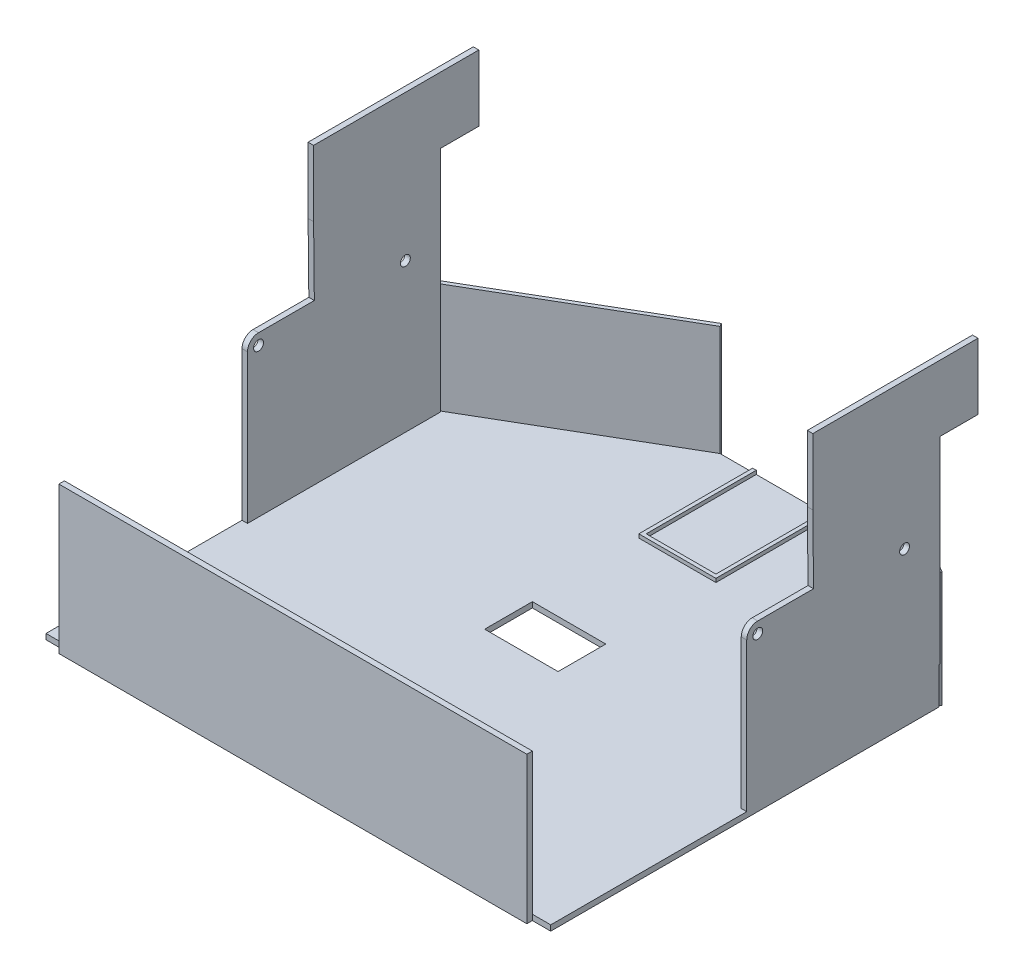
from build123d import *

# Parameters (mm, degrees)
SKETCH1_W                = 134
SKETCH1_H                = 134
SKETCH1_W_2              = 20
SKETCH1_H_2              = 13
BOSS_EXTRUDE1_DEPTH      = 1.5
BOSS_EXTRUDE2_DEPTH      = 45
SKETCH2_R                = 1.35
CUT_EXTRUDE1_DEPTH       = 137.5
SKETCH3_W                = 53.4
SKETCH3_H                = 43.5
CUT_EXTRUDE2_DEPTH       = 137.5
SKETCH4_W                = 140
SKETCH4_H                = 5
CUT_EXTRUDE3_DEPTH       = 1.5
SKETCH5_W                = 30
SKETCH5_H                = 43.5
CUT_EXTRUDE4_DEPTH       = 137.5
CUT_EXTRUDE5_DEPTH       = 10
BOSS_EXTRUDE3_DEPTH      = 1.5
BOSS_EXTRUDE4_DEPTH      = 1
BOSS_EXTRUDE5_DEPTH      = 30
BOSS_EXTRUDE5_DEPTH_BACK = 1.5
CUT_EXTRUDE6_DEPTH       = 137.5
SKETCH11_W               = 5
SKETCH11_H               = 40
CUT_EXTRUDE7_DEPTH       = 1.5
BOSS_EXTRUDE6_DEPTH      = 1.5


with BuildPart() as part:
    # Sketch1 → Boss-Extrude1 (new body)
    with BuildSketch(Plane(origin=(0, 0, 0), x_dir=(1, 0, 0), z_dir=(0, 1, 0))):
        Rectangle(SKETCH1_W, SKETCH1_H)
        Rectangle(SKETCH1_W_2, SKETCH1_H_2, mode=Mode.SUBTRACT)
        Polygon((-67, 67), (-67.25, 67.25), (-67.25, -67.25), (67.25, -67.25), (67.25, 67.25), (67, 67), (67, -67), (-67, -67), align=None)
    extrude(amount=BOSS_EXTRUDE1_DEPTH)

    # Sketch1_3 → Boss-Extrude2 (add)
    with BuildSketch(Plane(origin=(0, 0, 0), x_dir=(1, 0, 0), z_dir=(0, 1, 0))):
        Polygon((-67.25, -67.25), (-67.25, 67.25), (-68.75, 68.75), (-68.75, -68.75), (68.75, -68.75), (68.75, 68.75), (67.25, 67.25), (67.25, -67.25), align=None)
    extrude(amount=BOSS_EXTRUDE2_DEPTH)

    # Sketch2 → Cut-Extrude1 (cut)
    with BuildSketch(Plane.ZY.offset(68.75)):
        with Locations((10.85, 42)):
            Circle(SKETCH2_R)
        with Locations((-29.15, 42)):
            Circle(SKETCH2_R)
    extrude(amount=-CUT_EXTRUDE1_DEPTH, mode=Mode.SUBTRACT)

    # Sketch3 → Cut-Extrude2 (cut)
    with BuildSketch(Plane.ZY.offset(68.75)):
        with Locations((40.55, 23.25)):
            Rectangle(SKETCH3_W, SKETCH3_H)
    extrude(amount=-CUT_EXTRUDE2_DEPTH, mode=Mode.SUBTRACT)

    # Sketch4 → Cut-Extrude3 (cut)
    with BuildSketch(Plane.XY.offset(68.75)):
        with Locations((0, 42.5)):
            Rectangle(SKETCH4_W, SKETCH4_H)
    extrude(amount=-CUT_EXTRUDE3_DEPTH, mode=Mode.SUBTRACT)

    # Sketch5 → Cut-Extrude4 (cut)
    with BuildSketch(Plane.ZY.offset(68.75)):
        with Locations((-53.75, 23.25)):
            Rectangle(SKETCH5_W, SKETCH5_H)
    extrude(amount=-CUT_EXTRUDE4_DEPTH, mode=Mode.SUBTRACT)

    # Sketch6 → Cut-Extrude5 (cut)
    with BuildSketch(Plane(origin=(0, 0, 0), x_dir=(-1, 0, 0), z_dir=(0, -1, 0))):
        Polygon((67, 67), (68.75, 67), (68.75, 68.75), align=None)
        Polygon((19.386551984, 67), (68.75, 38.5), (68.75, 67), (67, 67), align=None)
        Polygon((-68.75, 38.5), (-19.386551984, 67), (-67, 67), (-68.75, 67), align=None)
        Polygon((-68.75, 67), (-67, 67), (-68.75, 68.75), align=None)
    extrude(amount=-CUT_EXTRUDE5_DEPTH, mode=Mode.SUBTRACT)


with BuildPart() as body_2:
    # Sketch7 → Boss-Extrude3 (new body)
    with BuildSketch(Plane(origin=(-68.75, 0, 0), x_dir=(0, 0, -1), z_dir=(-1, 0, 0))):
        Polygon((49.15, -63.7), (38.75, -63.7), (38.75, -45), (19.55, -45), (19.55, -63.7), (4.15, -63.7), (4.15, -81.7), (49.15, -81.7), align=None)
    boss_extrude3 = extrude(amount=-BOSS_EXTRUDE3_DEPTH)


with BuildPart() as part_1:
    add(part.part)

    # Mirror6: Boss-Extrude3 across plane
    add(boss_extrude3.mirror(Plane(origin=(0, 0, 0), x_dir=(0, 0, 1), z_dir=(1, 0, 0))))


with BuildPart() as body_2_1:
    add(body_2.part)

    # Combine1: union part
    add(part_1.part)

    # Sketch8 → Boss-Extrude4 (add)
    with BuildSketch(Plane(origin=(0, 1.5, 0), x_dir=(1, 0, 0), z_dir=(0, 1, 0))):
        Polygon((-9.5, 37), (-9.5, 67), (-10.5, 67), (-10.5, 36), (0, 36), (0, 37), align=None)
        Polygon((10.5, 67), (9.5, 67), (9.5, 37), (0, 37), (0, 36), (10.5, 36), align=None)
    extrude(amount=BOSS_EXTRUDE4_DEPTH)

    # Sketch9 → Boss-Extrude5 (add, two sides)
    with BuildSketch(Plane(origin=(0, 1.5, 0), x_dir=(1, 0, 0), z_dir=(0, 1, 0))) as boss_extrude5_sk:
        Polygon((-19.386551984, 67), (-68.25, 38.5), (-68.753822513, 39.363807198), (-19.890374497, 67.863807198), align=None)
        Polygon((19.890374497, 67.863807198), (68.753822513, 39.363807198), (68.25, 38.5), (19.386551984, 67), align=None)
    extrude(amount=BOSS_EXTRUDE5_DEPTH)
    extrude(boss_extrude5_sk.sketch, amount=-BOSS_EXTRUDE5_DEPTH_BACK)

    # Sketch10 → Cut-Extrude6 (cut)
    with BuildSketch(Plane(origin=(68.75, 0, 0), x_dir=(0, 0, -1), z_dir=(1, 0, 0))):
        with BuildLine():
            Line((-13.85, 42), (-13.85, 45))
            Line((-13.85, 45), (-10.85, 45))
            ThreePointArc((-10.85, 45), (-12.971320344, 44.121320344), (-13.85, 42))
        make_face()
    extrude(amount=-CUT_EXTRUDE6_DEPTH, mode=Mode.SUBTRACT)

    # Sketch11 → Cut-Extrude7 (cut)
    with BuildSketch(Plane.XY.offset(68.75)):
        with Locations((66.25, 20)):
            Rectangle(SKETCH11_W, SKETCH11_H)
        with Locations((-66.25, 20)):
            Rectangle(SKETCH11_W, SKETCH11_H)
    extrude(amount=-CUT_EXTRUDE7_DEPTH, mode=Mode.SUBTRACT)


with BuildPart() as body_2_2:
    # Sketch12 → Boss-Extrude6 (new body)
    with BuildSketch(Plane(origin=(68.75, 0, 0), x_dir=(0, 0, -1), z_dir=(1, 0, 0))):
        Polygon((4.15, 63.7), (4.35, 45), (19.55, 45), (19.55, 63.7), align=None)
    extrude(amount=-BOSS_EXTRUDE6_DEPTH)


with BuildPart() as body_3:
    # Mirror8: mirrored copy
    add(body_2_2.part.mirror(Plane(origin=(0, 0, 0), x_dir=(0, 0, 1), z_dir=(1, 0, 0))))


with BuildPart() as body_2_2_1:
    add(body_2_2.part)

    # Combine2: union body 3, body 2
    add(body_3.part)
    add(body_2_1.part)


solid = body_2_2_1.part
